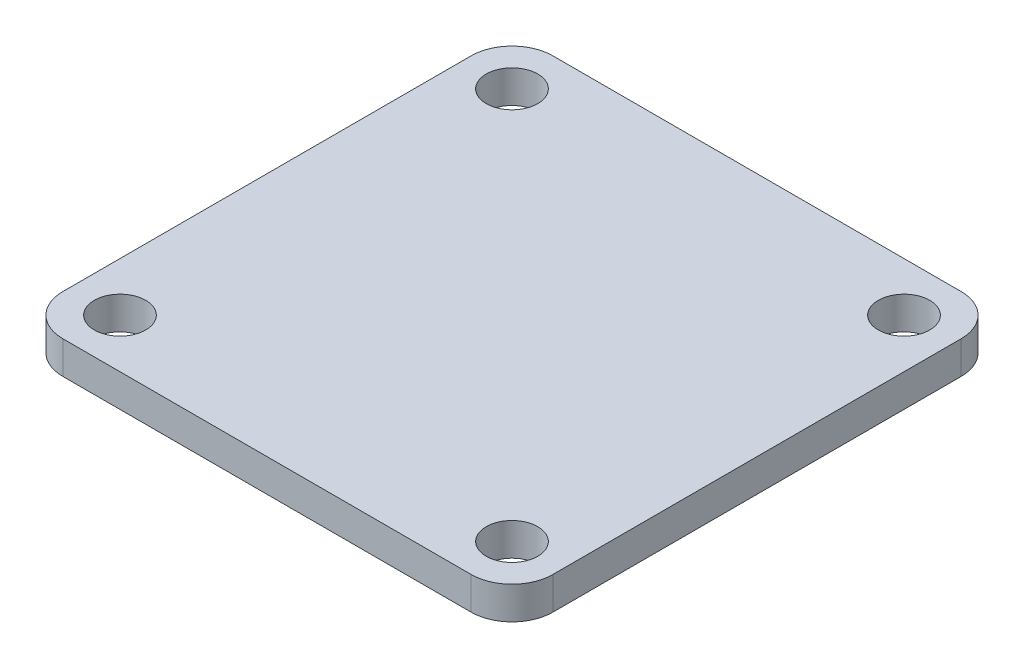
from build123d import *

# Parameters (mm, degrees)
SKETCH1_W           = 60
SKETCH1_H           = 60
SKETCH1_R           = 3.15
BOSS_EXTRUDE1_DEPTH = 4
FILLET1_R           = 5


with BuildPart() as part:
    # Sketch1 → Boss-Extrude1 (new body)
    with BuildSketch(Plane(origin=(0, 0, 0), x_dir=(1, 0, 0), z_dir=(0, 1, 0))):
        Rectangle(SKETCH1_W, SKETCH1_H)
        with Locations((-24, 24)):
            Circle(SKETCH1_R, mode=Mode.SUBTRACT)
        with Locations((24, 24)):
            Circle(SKETCH1_R, mode=Mode.SUBTRACT)
        with Locations((-24, -24)):
            Circle(SKETCH1_R, mode=Mode.SUBTRACT)
        with Locations((24, -24)):
            Circle(SKETCH1_R, mode=Mode.SUBTRACT)
    extrude(amount=BOSS_EXTRUDE1_DEPTH)

    # Fillet1
    fillet1_edges = [part.edges().sort_by_distance(p)[0] for p in [
        (30, 2, 30),
        (-30, 2, 30),
        (-30, 2, -30),
        (30, 2, -30),
    ]]
    fillet(fillet1_edges, radius=FILLET1_R)


solid = part.part
